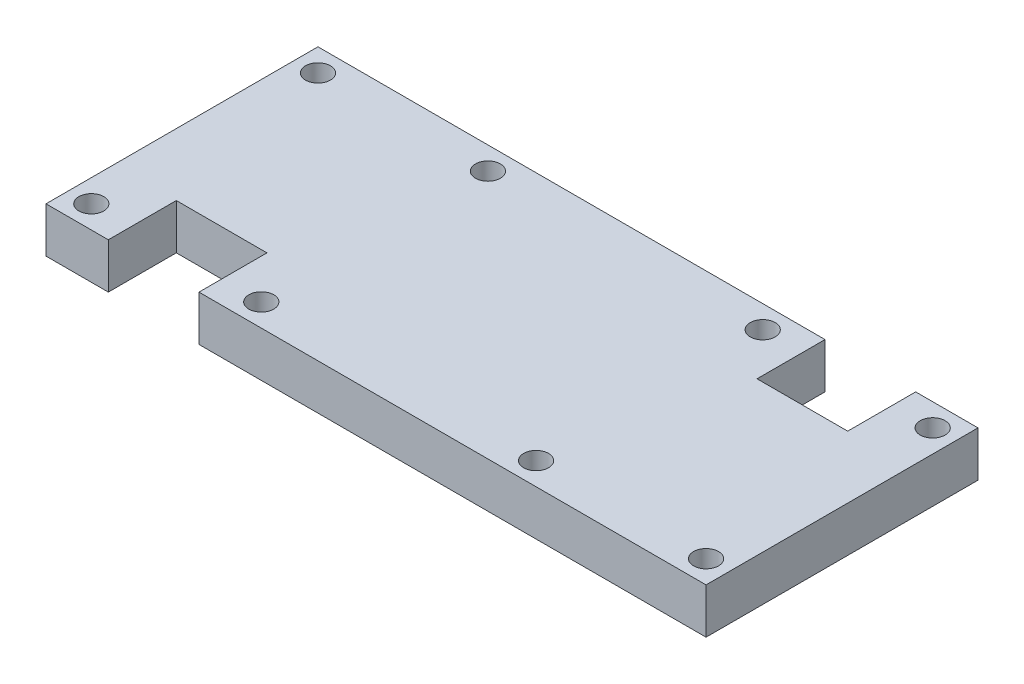
from build123d import *

# Parameters (mm, degrees)
BOSS_EXTRU_1_DEPTH      = 8
ESQUISSE3_R             = 2.2
ENL_V_MAT_EXTRU_1_DEPTH = 8
ESQUISSE5_W             = 16
ESQUISSE5_H             = 12
ENL_V_MAT_EXTRU_2_DEPTH = 8


with BuildPart() as part:
    # Esquisse1 → Boss.-Extru.1 (new body)
    with BuildSketch(Plane(origin=(0, 0, 0), x_dir=(1, 0, 0), z_dir=(0, 1, 0))):
        Polygon((0, 0), (38, 0), (78.5, 0), (116.5, 0), (116.5, 48), (78.5, 48), (38, 48), (0, 48), align=None)
    extrude(amount=BOSS_EXTRU_1_DEPTH)

    # Esquisse3 → Enlèv. mat.-Extru.1 (cut)
    with BuildSketch(Plane.XZ):
        with Locations((4, -4)):
            Circle(ESQUISSE3_R)
        with Locations((34, -4)):
            Circle(ESQUISSE3_R)
        with Locations((34, -44)):
            Circle(ESQUISSE3_R)
        with Locations((4, -44)):
            Circle(ESQUISSE3_R)
        with Locations((112.5, -44)):
            Circle(ESQUISSE3_R)
        with Locations((82.5, -44)):
            Circle(ESQUISSE3_R)
        with Locations((82.5, -4)):
            Circle(ESQUISSE3_R)
        with Locations((112.5, -4)):
            Circle(ESQUISSE3_R)
    extrude(amount=-ENL_V_MAT_EXTRU_1_DEPTH, mode=Mode.SUBTRACT)

    # Esquisse5 → Enlèv. mat.-Extru.2 (cut)
    with BuildSketch(Plane(origin=(0, 8, 0), x_dir=(1, 0, 0), z_dir=(0, 1, 0))):
        with Locations((97.5, 42)):
            Rectangle(ESQUISSE5_W, ESQUISSE5_H)
        with Locations((19, 6)):
            Rectangle(ESQUISSE5_W, ESQUISSE5_H)
    extrude(amount=-ENL_V_MAT_EXTRU_2_DEPTH, mode=Mode.SUBTRACT)


solid = part.part
